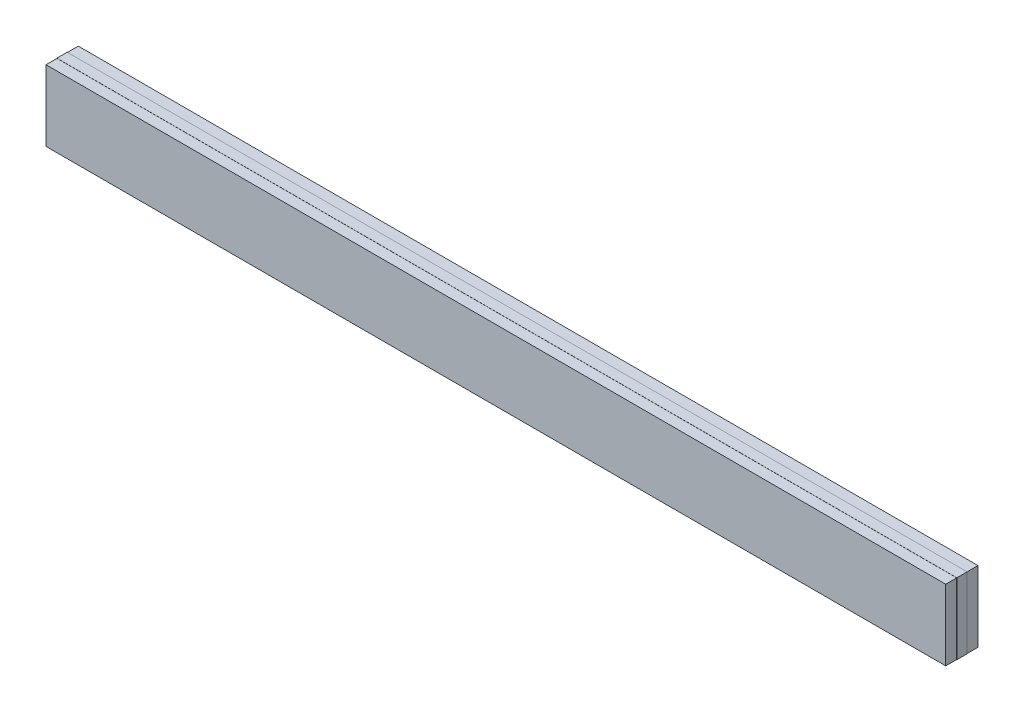
from build123d import *

# Parameters (mm, degrees)
SKETCH1_W           = 69.7
SKETCH1_H           = 5.5
BOSS_EXTRUDE1_DEPTH = 0.4
SKETCH2_W           = 69.68
SKETCH2_H           = 5.48
BOSS_EXTRUDE2_DEPTH = 0.85
SKETCH3_W           = 69.68
SKETCH3_H           = 5.48
BOSS_EXTRUDE3_DEPTH = 0.85


with BuildPart() as part:
    # Sketch1 → Boss-Extrude1 (new body, symmetric)
    with BuildSketch(Plane.XY):
        Rectangle(SKETCH1_W, SKETCH1_H)
    extrude(amount=BOSS_EXTRUDE1_DEPTH, both=True)

    # Sketch2 → Boss-Extrude2 (add)
    with BuildSketch(Plane.XY.offset(0.4)):
        Rectangle(SKETCH2_W, SKETCH2_H)
    extrude(amount=BOSS_EXTRUDE2_DEPTH)

    # Sketch3 → Boss-Extrude3 (add)
    with BuildSketch(Plane(origin=(0, 0, -0.4), x_dir=(-1, 0, 0), z_dir=(0, 0, -1))):
        Rectangle(SKETCH3_W, SKETCH3_H)
    extrude(amount=BOSS_EXTRUDE3_DEPTH)


solid = part.part
